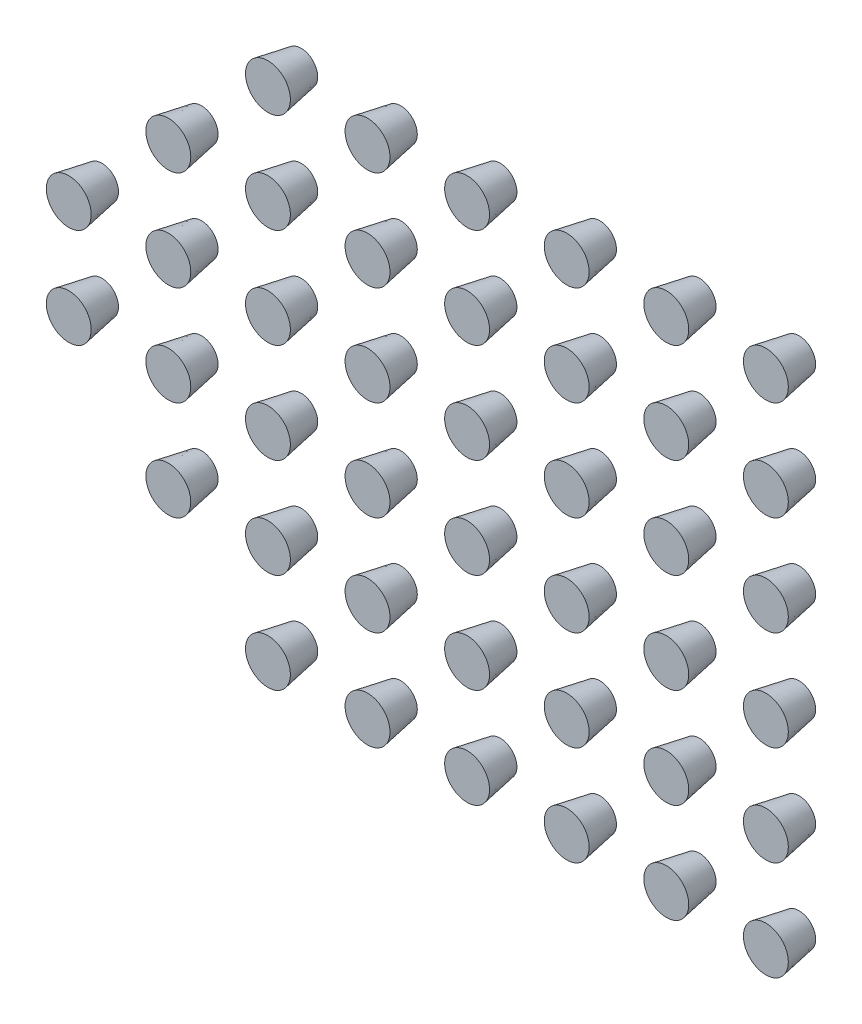
from build123d import *

# Parameters (mm, degrees)
SKETCH_1_R               = 0.5
EXTRUDE_1_DEPTH          = 1
EXTRUDE_1_TAPER          = -10
PATTERN_LINEAR_1_COUNT   = 6
PATTERN_LINEAR_1_PITCH   = 3
PATTERN_LINEAR_1_2_COUNT = 6
PATTERN_LINEAR_1_2_PITCH = 3
PATTERN_LINEAR_2_COUNT   = 2
PATTERN_LINEAR_2_PITCH   = 3
PATTERN_LINEAR_3_COUNT   = 2
PATTERN_LINEAR_3_PITCH   = 3


with BuildPart() as part:
    # 草图1 → 凸台-拉伸1 (new body)
    with BuildSketch(Plane.XY):
        Circle(SKETCH_1_R)
    extrude(amount=EXTRUDE_1_DEPTH, taper=EXTRUDE_1_TAPER)


with BuildPart() as pattern_linear_1_1:
    # 阵列(线性)1: pattern copy
    add(part.part.moved(Location(Vector(0, 1, 0) * (1 * PATTERN_LINEAR_1_PITCH))))


with BuildPart() as pattern_linear_1_2:
    # 阵列(线性)1: pattern copy
    add(part.part.moved(Location(Vector(0, 1, 0) * (2 * PATTERN_LINEAR_1_PITCH))))


with BuildPart() as pattern_linear_1_3:
    # 阵列(线性)1: pattern copy
    add(part.part.moved(Location(Vector(0, 1, 0) * (3 * PATTERN_LINEAR_1_PITCH))))


with BuildPart() as pattern_linear_1_4:
    # 阵列(线性)1: pattern copy
    add(part.part.moved(Location(Vector(0, 1, 0) * (4 * PATTERN_LINEAR_1_PITCH))))


with BuildPart() as pattern_linear_1_5:
    # 阵列(线性)1: pattern copy
    add(part.part.moved(Location(Vector(0, 1, 0) * (5 * PATTERN_LINEAR_1_PITCH))))


with BuildPart() as pattern_linear_1_2_1:
    # Pattern Linear 1 2: pattern copy
    add(part.part.moved(Location(Vector(1, 0, 0) * (1 * PATTERN_LINEAR_1_2_PITCH))))


with BuildPart() as pattern_linear_1_2_2:
    # Pattern Linear 1 2: pattern copy
    add(part.part.moved(Location(Vector(1, 0, 0) * (2 * PATTERN_LINEAR_1_2_PITCH))))


with BuildPart() as pattern_linear_1_2_3:
    # Pattern Linear 1 2: pattern copy
    add(part.part.moved(Location(Vector(1, 0, 0) * (3 * PATTERN_LINEAR_1_2_PITCH))))


with BuildPart() as pattern_linear_1_2_4:
    # Pattern Linear 1 2: pattern copy
    add(part.part.moved(Location(Vector(1, 0, 0) * (4 * PATTERN_LINEAR_1_2_PITCH))))


with BuildPart() as pattern_linear_1_2_5:
    # Pattern Linear 1 2: pattern copy
    add(part.part.moved(Location(Vector(1, 0, 0) * (5 * PATTERN_LINEAR_1_2_PITCH))))


with BuildPart() as pattern_linear_1_2_6:
    # Pattern Linear 1 2: pattern copy
    add(pattern_linear_1_1.part.moved(Location(Vector(1, 0, 0) * (1 * PATTERN_LINEAR_1_2_PITCH))))


with BuildPart() as pattern_linear_1_2_7:
    # Pattern Linear 1 2: pattern copy
    add(pattern_linear_1_1.part.moved(Location(Vector(1, 0, 0) * (2 * PATTERN_LINEAR_1_2_PITCH))))


with BuildPart() as pattern_linear_1_2_8:
    # Pattern Linear 1 2: pattern copy
    add(pattern_linear_1_1.part.moved(Location(Vector(1, 0, 0) * (3 * PATTERN_LINEAR_1_2_PITCH))))


with BuildPart() as pattern_linear_1_2_9:
    # Pattern Linear 1 2: pattern copy
    add(pattern_linear_1_1.part.moved(Location(Vector(1, 0, 0) * (4 * PATTERN_LINEAR_1_2_PITCH))))


with BuildPart() as pattern_linear_1_2_10:
    # Pattern Linear 1 2: pattern copy
    add(pattern_linear_1_1.part.moved(Location(Vector(1, 0, 0) * (5 * PATTERN_LINEAR_1_2_PITCH))))


with BuildPart() as pattern_linear_1_2_11:
    # Pattern Linear 1 2: pattern copy
    add(pattern_linear_1_2.part.moved(Location(Vector(1, 0, 0) * (1 * PATTERN_LINEAR_1_2_PITCH))))


with BuildPart() as pattern_linear_1_2_12:
    # Pattern Linear 1 2: pattern copy
    add(pattern_linear_1_2.part.moved(Location(Vector(1, 0, 0) * (2 * PATTERN_LINEAR_1_2_PITCH))))


with BuildPart() as pattern_linear_1_2_13:
    # Pattern Linear 1 2: pattern copy
    add(pattern_linear_1_2.part.moved(Location(Vector(1, 0, 0) * (3 * PATTERN_LINEAR_1_2_PITCH))))


with BuildPart() as pattern_linear_1_2_14:
    # Pattern Linear 1 2: pattern copy
    add(pattern_linear_1_2.part.moved(Location(Vector(1, 0, 0) * (4 * PATTERN_LINEAR_1_2_PITCH))))


with BuildPart() as pattern_linear_1_2_15:
    # Pattern Linear 1 2: pattern copy
    add(pattern_linear_1_2.part.moved(Location(Vector(1, 0, 0) * (5 * PATTERN_LINEAR_1_2_PITCH))))


with BuildPart() as pattern_linear_1_2_16:
    # Pattern Linear 1 2: pattern copy
    add(pattern_linear_1_3.part.moved(Location(Vector(1, 0, 0) * (1 * PATTERN_LINEAR_1_2_PITCH))))


with BuildPart() as pattern_linear_1_2_17:
    # Pattern Linear 1 2: pattern copy
    add(pattern_linear_1_3.part.moved(Location(Vector(1, 0, 0) * (2 * PATTERN_LINEAR_1_2_PITCH))))


with BuildPart() as pattern_linear_1_2_18:
    # Pattern Linear 1 2: pattern copy
    add(pattern_linear_1_3.part.moved(Location(Vector(1, 0, 0) * (3 * PATTERN_LINEAR_1_2_PITCH))))


with BuildPart() as pattern_linear_1_2_19:
    # Pattern Linear 1 2: pattern copy
    add(pattern_linear_1_3.part.moved(Location(Vector(1, 0, 0) * (4 * PATTERN_LINEAR_1_2_PITCH))))


with BuildPart() as pattern_linear_1_2_20:
    # Pattern Linear 1 2: pattern copy
    add(pattern_linear_1_3.part.moved(Location(Vector(1, 0, 0) * (5 * PATTERN_LINEAR_1_2_PITCH))))


with BuildPart() as pattern_linear_1_2_21:
    # Pattern Linear 1 2: pattern copy
    add(pattern_linear_1_4.part.moved(Location(Vector(1, 0, 0) * (1 * PATTERN_LINEAR_1_2_PITCH))))


with BuildPart() as pattern_linear_1_2_22:
    # Pattern Linear 1 2: pattern copy
    add(pattern_linear_1_4.part.moved(Location(Vector(1, 0, 0) * (2 * PATTERN_LINEAR_1_2_PITCH))))


with BuildPart() as pattern_linear_1_2_23:
    # Pattern Linear 1 2: pattern copy
    add(pattern_linear_1_4.part.moved(Location(Vector(1, 0, 0) * (3 * PATTERN_LINEAR_1_2_PITCH))))


with BuildPart() as pattern_linear_1_2_24:
    # Pattern Linear 1 2: pattern copy
    add(pattern_linear_1_4.part.moved(Location(Vector(1, 0, 0) * (4 * PATTERN_LINEAR_1_2_PITCH))))


with BuildPart() as pattern_linear_1_2_25:
    # Pattern Linear 1 2: pattern copy
    add(pattern_linear_1_4.part.moved(Location(Vector(1, 0, 0) * (5 * PATTERN_LINEAR_1_2_PITCH))))


with BuildPart() as pattern_linear_1_2_26:
    # Pattern Linear 1 2: pattern copy
    add(pattern_linear_1_5.part.moved(Location(Vector(1, 0, 0) * (1 * PATTERN_LINEAR_1_2_PITCH))))


with BuildPart() as pattern_linear_1_2_27:
    # Pattern Linear 1 2: pattern copy
    add(pattern_linear_1_5.part.moved(Location(Vector(1, 0, 0) * (2 * PATTERN_LINEAR_1_2_PITCH))))


with BuildPart() as pattern_linear_1_2_28:
    # Pattern Linear 1 2: pattern copy
    add(pattern_linear_1_5.part.moved(Location(Vector(1, 0, 0) * (3 * PATTERN_LINEAR_1_2_PITCH))))


with BuildPart() as pattern_linear_1_2_29:
    # Pattern Linear 1 2: pattern copy
    add(pattern_linear_1_5.part.moved(Location(Vector(1, 0, 0) * (4 * PATTERN_LINEAR_1_2_PITCH))))


with BuildPart() as pattern_linear_1_2_30:
    # Pattern Linear 1 2: pattern copy
    add(pattern_linear_1_5.part.moved(Location(Vector(1, 0, 0) * (5 * PATTERN_LINEAR_1_2_PITCH))))


with BuildPart() as pattern_linear_2_1:
    # 阵列(线性)2: pattern copy
    add(pattern_linear_1_4.part.moved(Location(Vector(-1, 0, 0) * (1 * PATTERN_LINEAR_2_PITCH))))


with BuildPart() as pattern_linear_2_2:
    # 阵列(线性)2: pattern copy
    add(pattern_linear_1_3.part.moved(Location(Vector(-1, 0, 0) * (1 * PATTERN_LINEAR_2_PITCH))))


with BuildPart() as pattern_linear_2_3:
    # 阵列(线性)2: pattern copy
    add(pattern_linear_1_2.part.moved(Location(Vector(-1, 0, 0) * (1 * PATTERN_LINEAR_2_PITCH))))


with BuildPart() as pattern_linear_2_4:
    # 阵列(线性)2: pattern copy
    add(pattern_linear_1_1.part.moved(Location(Vector(-1, 0, 0) * (1 * PATTERN_LINEAR_2_PITCH))))


with BuildPart() as pattern_linear_3_1:
    # 阵列(线性)3: pattern copy
    add(pattern_linear_2_2.part.moved(Location(Vector(-1, 0, 0) * (1 * PATTERN_LINEAR_3_PITCH))))


with BuildPart() as pattern_linear_3_2:
    # 阵列(线性)3: pattern copy
    add(pattern_linear_2_3.part.moved(Location(Vector(-1, 0, 0) * (1 * PATTERN_LINEAR_3_PITCH))))


solid = Compound([part.part, pattern_linear_1_1.part, pattern_linear_1_2.part, pattern_linear_1_3.part, pattern_linear_1_4.part, pattern_linear_1_5.part, pattern_linear_1_2_1.part, pattern_linear_1_2_2.part, pattern_linear_1_2_3.part, pattern_linear_1_2_4.part, pattern_linear_1_2_5.part, pattern_linear_1_2_6.part, pattern_linear_1_2_7.part, pattern_linear_1_2_8.part, pattern_linear_1_2_9.part, pattern_linear_1_2_10.part, pattern_linear_1_2_11.part, pattern_linear_1_2_12.part, pattern_linear_1_2_13.part, pattern_linear_1_2_14.part, pattern_linear_1_2_15.part, pattern_linear_1_2_16.part, pattern_linear_1_2_17.part, pattern_linear_1_2_18.part, pattern_linear_1_2_19.part, pattern_linear_1_2_20.part, pattern_linear_1_2_21.part, pattern_linear_1_2_22.part, pattern_linear_1_2_23.part, pattern_linear_1_2_24.part, pattern_linear_1_2_25.part, pattern_linear_1_2_26.part, pattern_linear_1_2_27.part, pattern_linear_1_2_28.part, pattern_linear_1_2_29.part, pattern_linear_1_2_30.part, pattern_linear_2_1.part, pattern_linear_2_2.part, pattern_linear_2_3.part, pattern_linear_2_4.part, pattern_linear_3_1.part, pattern_linear_3_2.part])
